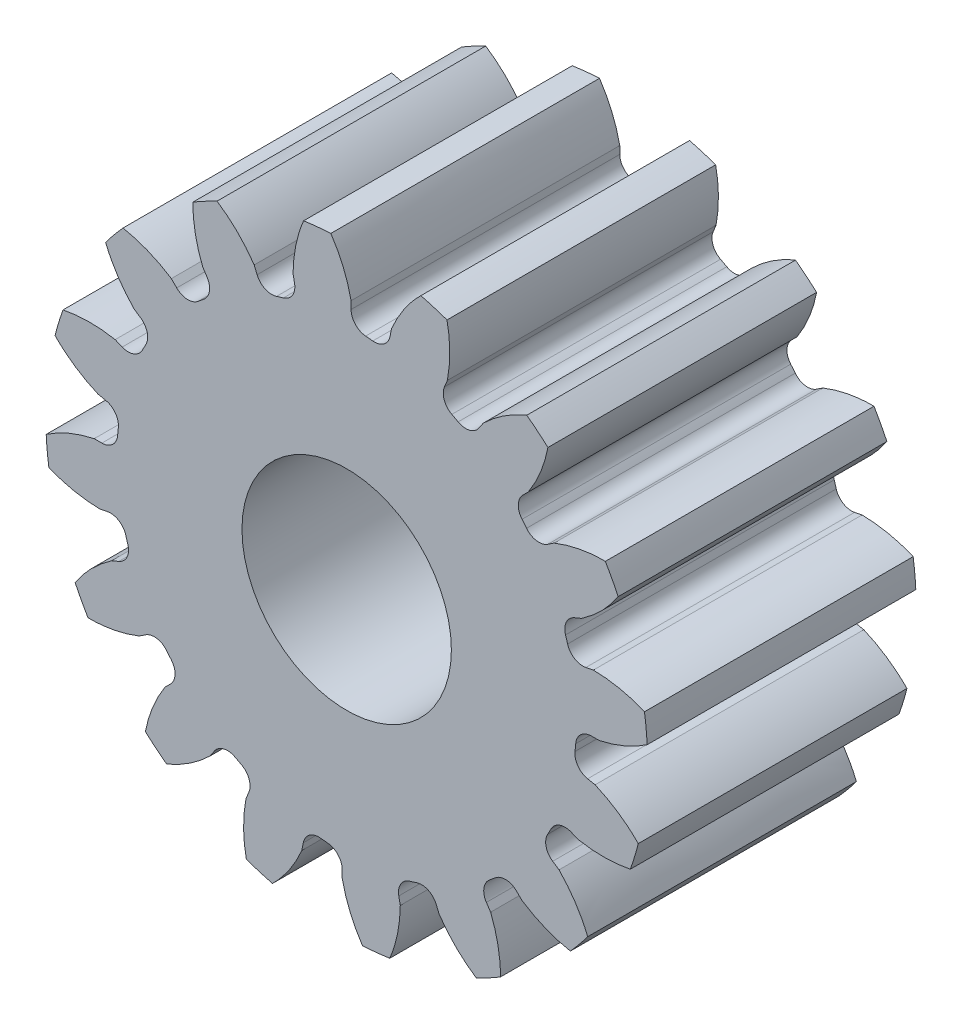
from build123d import *

# Parameters (mm, degrees)
SKETCH1_R                = 7.112
BOSS_EXTRUDE1_DEPTH      = 6.35
CUT_EXTRUDE1_DEPTH       = 7.35
FILLET1_R                = 0.37404675
CIRPATTERN1_COUNT        = 16
FILLET1_OF_CIRPATTERN1_R = 0.37404675
SKETCH5_R                = 2.475
CUT_EXTRUDE2_DEPTH       = 7.3500049


with BuildPart() as part:
    # Sketch1 → Boss-Extrude1 (new body)
    with BuildSketch(Plane.XY):
        Circle(SKETCH1_R)
    extrude(amount=-BOSS_EXTRUDE1_DEPTH)

    # Sketch4 → Cut-Extrude1 (cut, through all)
    with BuildSketch(Plane.XY):
        with BuildLine():
            Line((0.105411749, 5.966116986), (0.105411749, 5.43060829))
            ThreePointArc((0.105411749, 5.43060829), (0.532394203, 5.405476339), (0.956075283, 5.346825048))
            Line((0.956075283, 5.346825048), (1.060548088, 5.872044046))
            add(Edge.make_bspline(
                [(3.260501867, 7.787545628), (1.642921163, 7.230549574), (1.060548088, 5.872044046)],
                knots=[0, 0, 0, 1, 1, 1], degree=2))
            ThreePointArc((3.260501867, 7.787545628), (0.827517053, 8.40190186), (-1.678573655, 8.274003253))
            add(Edge.make_bspline(
                [(-1.678573655, 8.274003253), (-0.200739245, 7.412134702), (0.105411749, 5.966116986)],
                knots=[0, 0, 0, 1, 1, 1], degree=2))
        make_face()
    cut_extrude1 = extrude(amount=-CUT_EXTRUDE1_DEPTH, mode=Mode.SUBTRACT)

    # Fillet1
    fillet1_edges = [part.edges().sort_by_distance(p)[0] for p in [
        (0.956075283, 5.346825048, -3.175),
        (0.105411749, 5.43060829, -3.175),
    ]]
    fillet(fillet1_edges, radius=FILLET1_R)

    # CirPattern1: Cut-Extrude1 ×16 about axis
    cirpattern1_axis = Axis((0, 0, -6.35), (0, 0, 1))
    for i in range(1, CIRPATTERN1_COUNT):
        add(cut_extrude1.rotate(cirpattern1_axis, i * 360 / CIRPATTERN1_COUNT), mode=Mode.SUBTRACT)

    # Fillet1 of CirPattern1
    fillet1_of_cirpattern1_edges = [part.edges().sort_by_distance(p)[0] for p in [
        (-1.162842976, 5.305696396, -3.175),
        (-1.980816062, 5.057567178, -3.175),
        (-3.104728933, 4.456823565, -3.175),
        (-3.765482585, 3.914557311, -3.175),
        (-4.573948055, 2.929439747, -3.175),
        (-4.976888518, 2.175591578, -3.175),
        (-5.346825048, 0.956075283, -3.175),
        (-5.43060829, 0.105411749, -3.175),
        (-5.305696396, -1.162842976, -3.175),
        (-5.057567178, -1.980816062, -3.175),
        (-4.456823565, -3.104728933, -3.175),
        (-3.914557311, -3.765482585, -3.175),
        (-2.929439747, -4.573948055, -3.175),
        (-2.175591578, -4.976888518, -3.175),
        (-0.956075283, -5.346825048, -3.175),
        (-0.105411749, -5.43060829, -3.175),
        (1.162842976, -5.305696396, -3.175),
        (1.980816062, -5.057567178, -3.175),
        (3.104728933, -4.456823565, -3.175),
        (3.765482585, -3.914557311, -3.175),
        (4.573948055, -2.929439747, -3.175),
        (4.976888518, -2.175591578, -3.175),
        (5.346825048, -0.956075283, -3.175),
        (5.43060829, -0.105411749, -3.175),
        (5.305696396, 1.162842976, -3.175),
        (5.057567178, 1.980816062, -3.175),
        (4.456823565, 3.104728933, -3.175),
        (3.914557311, 3.765482585, -3.175),
        (2.929439747, 4.573948055, -3.175),
        (2.175591578, 4.976888518, -3.175),
    ]]
    fillet(fillet1_of_cirpattern1_edges, radius=FILLET1_OF_CIRPATTERN1_R)

    # Sketch5 → Cut-Extrude2 (cut, through all)
    with BuildSketch(Plane.XY):
        Circle(SKETCH5_R)
    extrude(amount=-CUT_EXTRUDE2_DEPTH, mode=Mode.SUBTRACT)


solid = part.part
